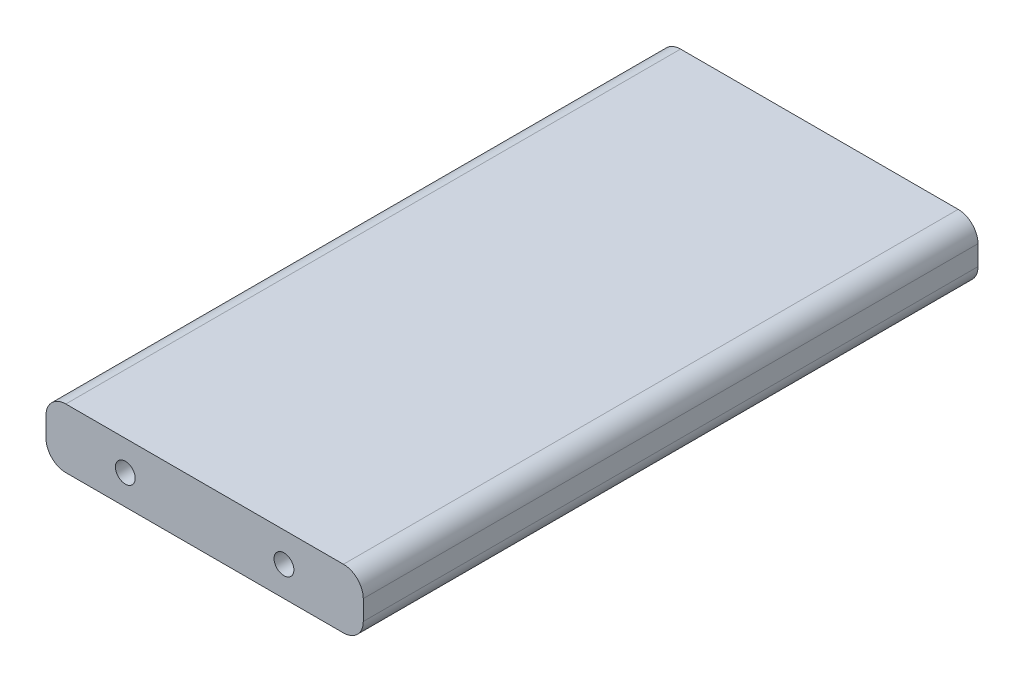
from build123d import *

# Parameters (mm, degrees)
BOSS_EXTRUDE1_DEPTH = 98.425
SKETCH2_R           = 3.175
CUT_EXTRUDE1_DEPTH  = 12.7
FILLET1_R           = 6.35


with BuildPart() as part:
    # Sketch1 → Boss-Extrude1 (new body, symmetric)
    with BuildSketch(Plane.XY):
        with BuildLine():
            Line((44.45, 9.525), (50.8, 9.525))
            Line((50.8, 9.525), (50.8, 3.175))
            Line((50.8, 3.175), (50.8, -3.175))
            Line((50.8, -3.175), (50.8, -9.525))
            Line((50.8, -9.525), (44.45, -9.525))
            Line((44.45, -9.525), (-44.45, -9.525))
            ThreePointArc((-44.45, -9.525), (-48.940128061, -7.665128061), (-50.8, -3.175))
            Line((-50.8, -3.175), (-50.8, 3.175))
            ThreePointArc((-50.8, 3.175), (-48.940128061, 7.665128061), (-44.45, 9.525))
            Line((-44.45, 9.525), (44.45, 9.525))
        make_face()
    extrude(amount=BOSS_EXTRUDE1_DEPTH, both=True)

    # Sketch2 → Cut-Extrude1 (cut)
    with BuildSketch(Plane.XY.offset(98.425)):
        with Locations((-25.4, 0)):
            Circle(SKETCH2_R)
        with Locations((25.4, 0)):
            Circle(SKETCH2_R)
    cut_extrude1 = extrude(amount=-CUT_EXTRUDE1_DEPTH, mode=Mode.SUBTRACT)

    # Fillet1
    fillet1_edges = [part.edges().sort_by_distance(p)[0] for p in [
        (50.8, -9.525, 0),
        (50.8, 9.525, 0),
    ]]
    fillet(fillet1_edges, radius=FILLET1_R)

    # Mirror1: Cut-Extrude1 across plane
    add(cut_extrude1.mirror(Plane.XY), mode=Mode.SUBTRACT)


solid = part.part
